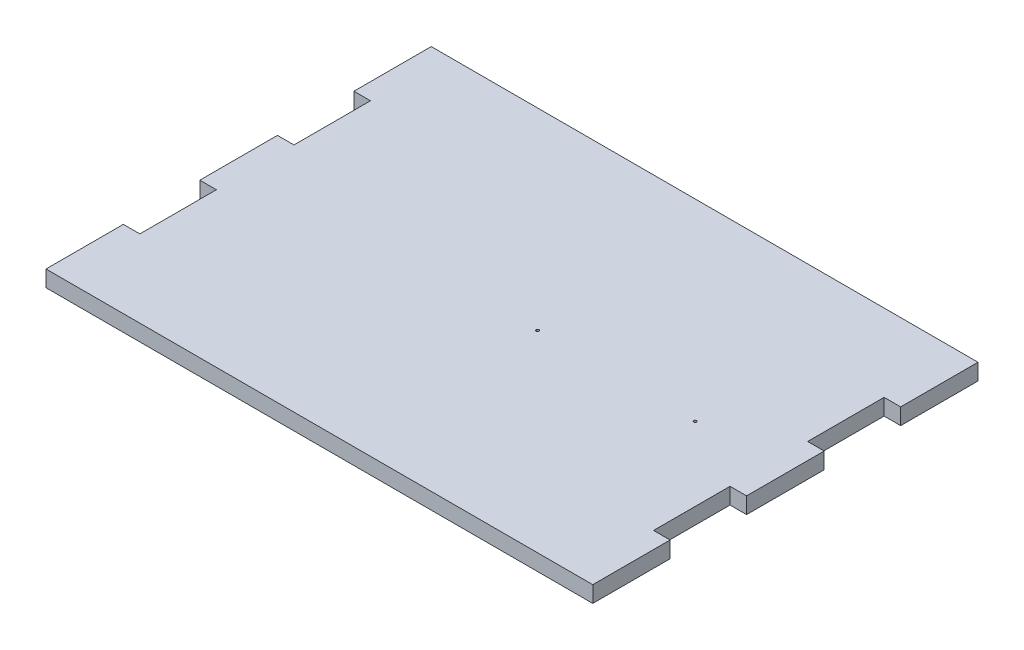
from build123d import *

# Parameters (mm, degrees)
SKETCH3_W           = 192
SKETCH3_H           = 135
BOSS_EXTRUDE1_DEPTH = 5.7
SKETCH11_R          = 0.5
CUT_EXTRUDE2_DEPTH  = 33
CUT_EXTRUDE3_DEPTH  = 22


with BuildPart() as part:
    # Sketch3 → Boss-Extrude1 (new body)
    with BuildSketch(Plane(origin=(0, 0, 0), x_dir=(1, 0, 0), z_dir=(0, 1, 0))):
        with Locations((90, 53.5)):
            Rectangle(SKETCH3_W, SKETCH3_H)
    extrude(amount=BOSS_EXTRUDE1_DEPTH)

    # Sketch11 → Cut-Extrude2 (cut)
    with BuildSketch(Plane(origin=(0, 0, 0), x_dir=(1, 0, 0), z_dir=(0, 1, 0))):
        with Locations((99, 53.5)):
            Circle(SKETCH11_R)
        with Locations((154.2, 53.5)):
            Circle(SKETCH11_R)
    extrude(amount=CUT_EXTRUDE2_DEPTH, mode=Mode.SUBTRACT)

    # Sketch12 → Cut-Extrude3 (cut)
    with BuildSketch(Plane(origin=(0, 0, 0), x_dir=(1, 0, 0), z_dir=(0, 1, 0))):
        Polygon((-5.8, 121), (-5.8, 93.9), (0, 93.9), (0, 67.1), (-5.8, 67.1), (-5.8, 39.9), (0, 39.9), (0, 13.1), (-5.8, 13.1), (-5.8, -14), (-9.8, -14), (-9.8, 121), align=None)
        Polygon((189.8, 121), (185.8, 121), (185.8, 93.9), (180, 93.9), (180, 67.1), (185.8, 67.1), (185.8, 39.9), (180, 39.9), (180, 13.1), (185.8, 13.1), (185.8, -14), (189.8, -14), align=None)
    extrude(amount=CUT_EXTRUDE3_DEPTH, mode=Mode.SUBTRACT)


solid = part.part
